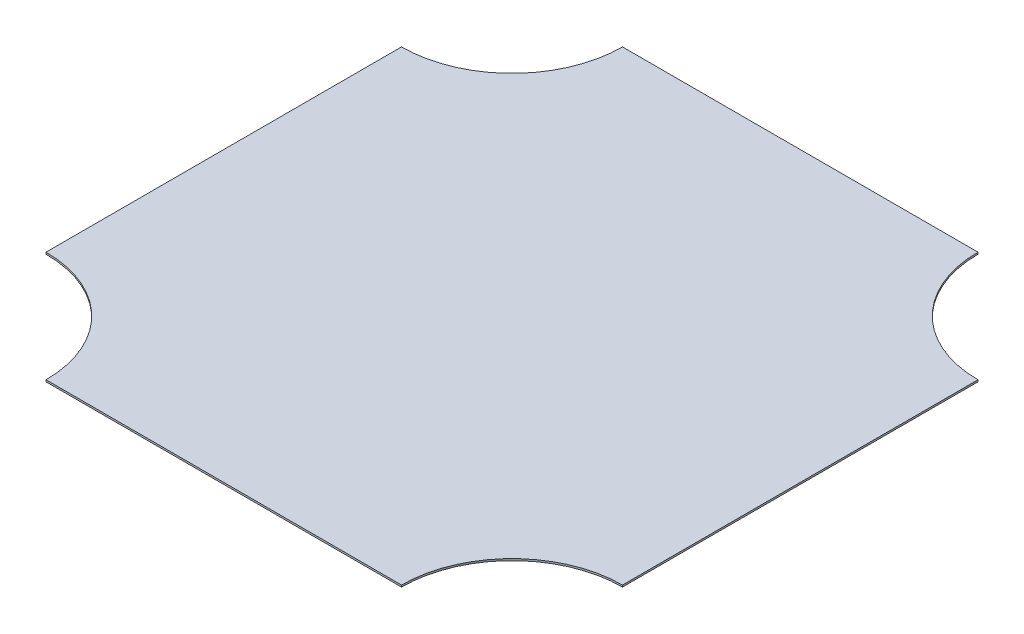
from build123d import *

# Parameters (mm, degrees)
SKETCH1_W           = 762
SKETCH1_H           = 762
BOSS_EXTRUDE1_DEPTH = 2.38125
CUT_EXTRUDE1_DEPTH  = 3.38125


with BuildPart() as part:
    # Sketch1 → Boss-Extrude1 (new body)
    with BuildSketch(Plane(origin=(0, 0, 0), x_dir=(1, 0, 0), z_dir=(0, 1, 0))):
        Rectangle(SKETCH1_W, SKETCH1_H)
    extrude(amount=BOSS_EXTRUDE1_DEPTH)

    # Sketch2 → Cut-Extrude1 (cut, through all)
    with BuildSketch(Plane(origin=(0, 2.38125, 0), x_dir=(1, 0, 0), z_dir=(0, 1, 0))):
        with BuildLine():
            Line((234.95, 381), (381, 381))
            Line((381, 381), (381, 234.95))
            ThreePointArc((381, 234.95), (277.727054608, 277.727054608), (234.95, 381))
        make_face()
        with BuildLine():
            Line((381, -234.95), (381, -381))
            Line((381, -381), (234.95, -381))
            ThreePointArc((234.95, -381), (277.727054608, -277.727054608), (381, -234.95))
        make_face()
        with BuildLine():
            Line((-234.95, -381), (-381, -381))
            Line((-381, -381), (-381, -234.95))
            ThreePointArc((-381, -234.95), (-277.727054608, -277.727054608), (-234.95, -381))
        make_face()
        with BuildLine():
            Line((-381, 234.95), (-381, 381))
            Line((-381, 381), (-234.95, 381))
            ThreePointArc((-234.95, 381), (-277.727054608, 277.727054608), (-381, 234.95))
        make_face()
    extrude(amount=-CUT_EXTRUDE1_DEPTH, mode=Mode.SUBTRACT)


solid = part.part
